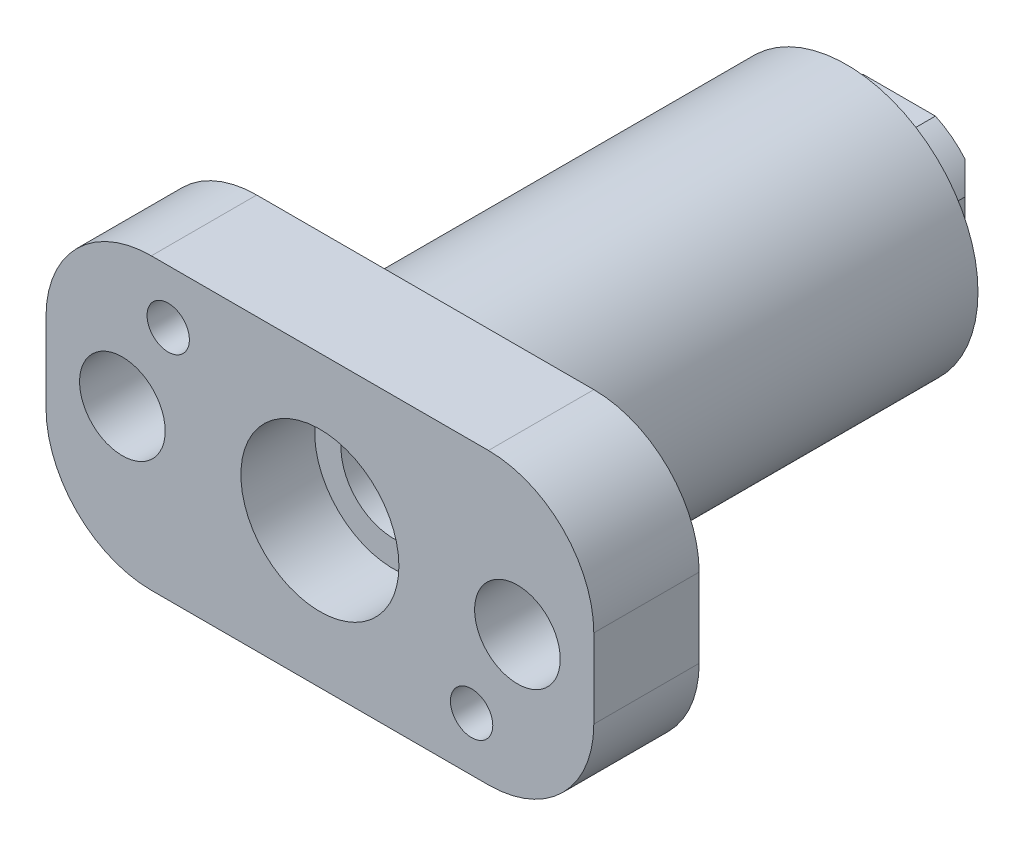
from build123d import *

# Parameters (mm, degrees)
SKETCH1_R                        = 15.8369
EXTRUDE1_DEPTH                   = 25.4
SKETCH2_W                        = 66.04
SKETCH2_H                        = 34.925
EXTRUDE2_DEPTH                   = 12.7
SKETCH4_R                        = 6.35
CUT_EXTRUDE1_DEPTH               = 70.85
SKETCH6_R                        = 9.525
CUT_EXTRUDE5_DEPTH               = 8.89
SKETCH7_W                        = 18.923
SKETCH7_H                        = 18.923
SKETCH7_R                        = 6.35
EXTRUDE3_DEPTH                   = 6.35
SKETCH9_OUTSIDE_W                = 88.494
SKETCH9_OUTSIDE_H                = 57.38
SKETCH9_OUTSIDE_R                = 10.414
CUT_EXTRUDE7_DEPTH               = 6.35
FILLET1_R                        = 12.7
F_1_4_20_TAPPED_HOLE1_D          = 5.1054
F_13_32_0_40625_DIAMETER_HOLE1_D = 10.31875
CHAMFER2_SIZE                    = 1.524


with BuildPart() as part:
    # Sketch1 → Extrude1 (new body)
    with BuildSketch(Plane.XY):
        Circle(SKETCH1_R)
    extrude(amount=EXTRUDE1_DEPTH)

    # Sketch2 → Extrude2 (add)
    with BuildSketch(Plane.XY.offset(25.4)):
        Rectangle(SKETCH2_W, SKETCH2_H)
    extrude(amount=EXTRUDE2_DEPTH)

    # Sketch3 → Revolve1 (revolve)
    with BuildSketch(Plane(origin=(0, 0, 0), x_dir=(1, 0, 0), z_dir=(0, 1, 0))):
        Polygon((0, 0), (0, 31.75), (9.4615, 31.75), (9.4615, 25.4), (15.8369, 25.4), (15.8369, 0), align=None)
    revolve(axis=Axis((0, 0, 0), (0, 0, -1)))

    # Sketch4 → Cut-Extrude1 (cut, through all)
    with BuildSketch(Plane.XY.offset(38.1)):
        Circle(SKETCH4_R)
    extrude(amount=-CUT_EXTRUDE1_DEPTH, mode=Mode.SUBTRACT)

    # Sketch6 → Cut-Extrude5 (cut)
    with BuildSketch(Plane.XY.offset(38.1)):
        Circle(SKETCH6_R)
    extrude(amount=-CUT_EXTRUDE5_DEPTH, mode=Mode.SUBTRACT)

    # Sketch7 → Extrude3 (add)
    with BuildSketch(Plane(origin=(0, 0, -25.4), x_dir=(-1, 0, 0), z_dir=(0, 0, -1))):
        Rectangle(SKETCH7_W, SKETCH7_H)
        with Locations(Location((0, 0, 0), (0, 0, 180))):  # turned: the seam where the file's is
            Circle(SKETCH7_R, mode=Mode.SUBTRACT)
    extrude(amount=EXTRUDE3_DEPTH)

    # Sketch9 outside → Cut-Extrude7 (cut)
    with BuildSketch(Plane(origin=(0, 0, -31.75), x_dir=(-1, 0, 0), z_dir=(0, 0, -1))):
        Rectangle(SKETCH9_OUTSIDE_W, SKETCH9_OUTSIDE_H)
        Circle(SKETCH9_OUTSIDE_R, mode=Mode.SUBTRACT)
    extrude(amount=-CUT_EXTRUDE7_DEPTH, mode=Mode.SUBTRACT)

    # Fillet1
    fillet1_edges = [part.edges().sort_by_distance(p)[0] for p in [
        (-33.02, 17.4625, 31.75),
        (-33.02, -17.4625, 31.75),
        (33.02, -17.4625, 31.75),
        (33.02, 17.4625, 31.75),
    ]]
    fillet(fillet1_edges, radius=FILLET1_R)

    # 1/4-20 Tapped Hole1 (through all)
    with Locations(Plane.XY.offset(38.1)):
        with Locations((18.288, -10.9855), (-18.288, 10.9855)):
            Hole(F_1_4_20_TAPPED_HOLE1_D / 2)

    # 13/32 (0.40625) Diameter Hole1 (through all)
    with Locations(Plane.XY.offset(38.1)):
        with Locations((-23.8125, 0), (23.8125, 0)):
            Hole(F_13_32_0_40625_DIAMETER_HOLE1_D / 2)

    # Chamfer2
    chamfer2_edges = [part.edges().sort_by_distance(p)[0] for p in [
        (9.4615, 0, -31.75),
        (-9.4615, 0, -31.75),
    ]]
    chamfer(chamfer2_edges, length=CHAMFER2_SIZE)


solid = part.part
